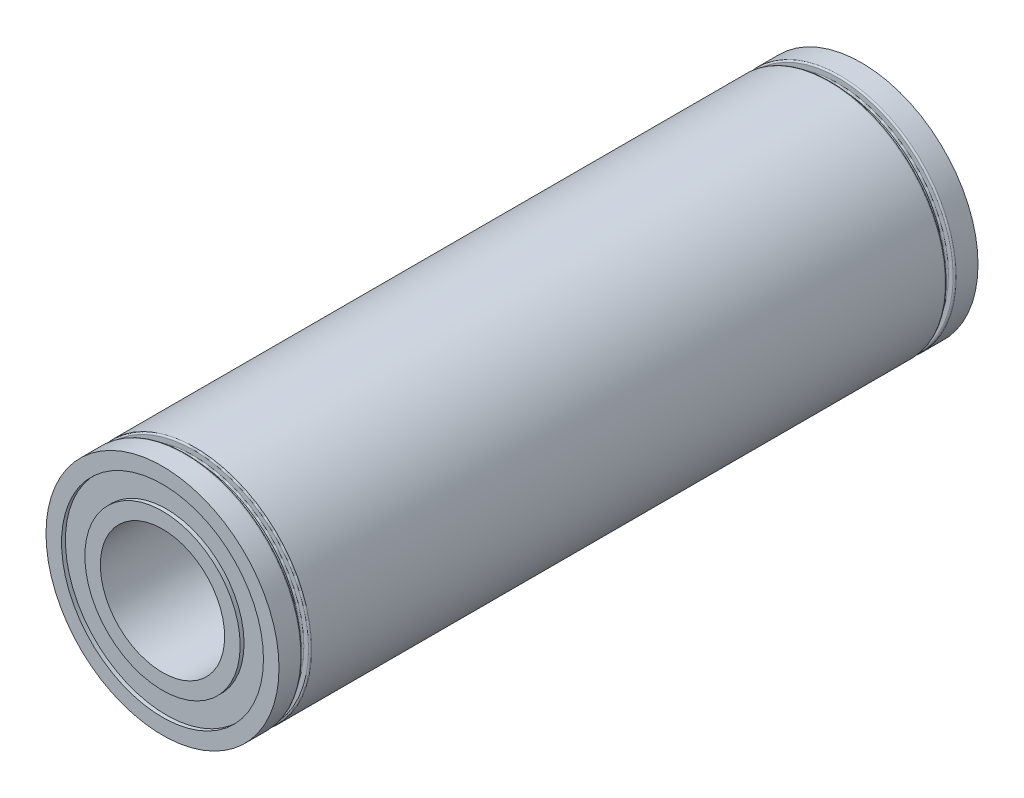
from build123d import *

# Parameters (mm, degrees)
SKETCH2_R             = 7.5
SKETCH2_R_2           = 6.5
BOSS_EXTRUDE1_DEPTH   = 22.5
SKETCH2_R_3           = 5
SKETCH2_R_4           = 4
BOSS_EXTRUDE1_2_DEPTH = 22.5
SKETCH2_3_R           = 6.5
SKETCH2_3_R_2         = 5
BOSS_EXTRUDE2_DEPTH   = 22.25
SKETCH3_W             = 1
SKETCH3_H             = 0.5
FILLET1_R             = 0.1


with BuildPart() as part:
    # Sketch2 → Boss-Extrude1 (new, symmetric)
    with BuildSketch(Plane.XY):
        Circle(SKETCH2_R)
        Circle(SKETCH2_R_2, mode=Mode.SUBTRACT)
    extrude(amount=BOSS_EXTRUDE1_DEPTH, both=True)



with BuildPart() as body_2:
    # Sketch2 → Boss-Extrude1 2 (new, symmetric)
    with BuildSketch(Plane.XY):
        Circle(SKETCH2_R_3)
        Circle(SKETCH2_R_4, mode=Mode.SUBTRACT)
    extrude(amount=BOSS_EXTRUDE1_2_DEPTH, both=True)


with BuildPart() as part_1:
    add(part.part)

    add(body_2.part)  # Boss-Extrude2 merges body 2
    # Sketch2_3 → Boss-Extrude2 (add, symmetric)
    with BuildSketch(Plane.XY):
        Circle(SKETCH2_3_R)
        Circle(SKETCH2_3_R_2, mode=Mode.SUBTRACT)
    extrude(amount=BOSS_EXTRUDE2_DEPTH, both=True)

    # Sketch3 → Cut-Revolve1 (revolve, cut)
    with BuildSketch(Plane(origin=(0, 0, 0), x_dir=(1, 0, 0), z_dir=(0, 1, 0))):
        with Locations((7.5, 20.75)):
            Rectangle(SKETCH3_W, SKETCH3_H)
        with Locations((7.5, -20.75)):
            Rectangle(SKETCH3_W, SKETCH3_H)
    revolve(axis=Axis((0, 0, -22.5), (0, 0, 1)), mode=Mode.SUBTRACT)

    # Fillet1
    fillet1_edges = [part_1.edges().sort_by_distance(p)[0] for p in [
        (-7, 0, -21),
        (-7.5, 0, -21),
        (-7, 0, -20.5),
        (-7.5, 0, -20.5),
        (-7, 0, 21),
        (-7, 0, 20.5),
        (-7.5, 0, 20.5),
        (-7.5, 0, 21),
    ]]
    fillet(fillet1_edges, radius=FILLET1_R)


solid = part_1.part
